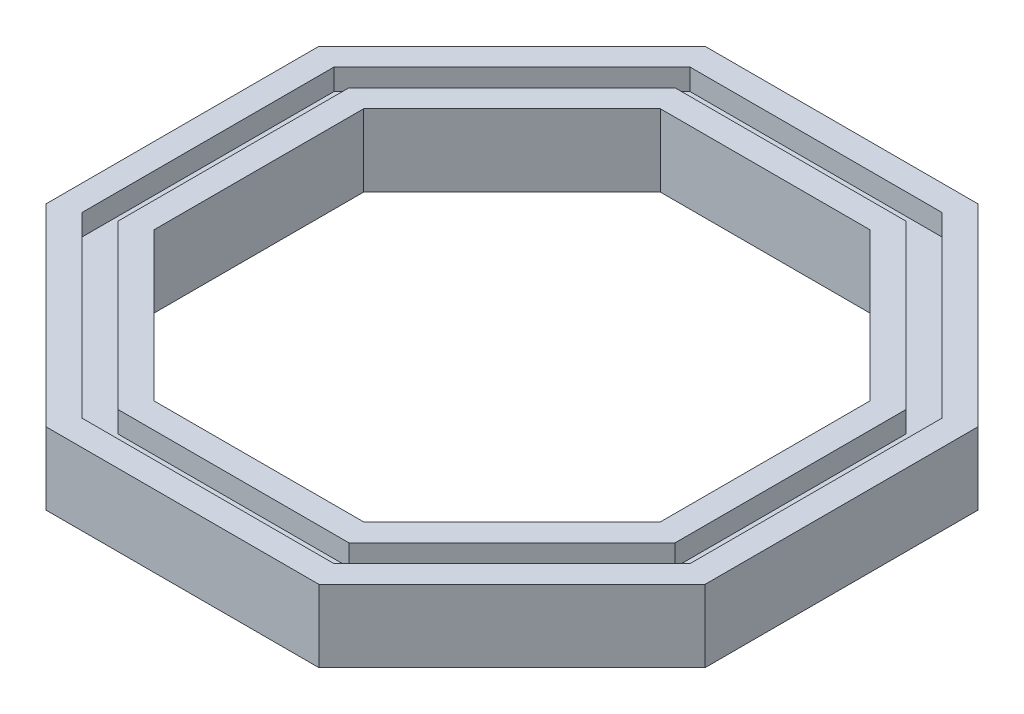
from build123d import *

# Parameters (mm, degrees)
EXTRUDE_1_DEPTH     = 1.7
CUT_EXTRUDE_3_DEPTH = 1
CUT_EXTRUDE_4_DEPTH = 2.7


with BuildPart() as part:
    # 스케치1 → 보스-돌출1 (new body)
    with BuildSketch(Plane(origin=(0, 0, 0), x_dir=(1, 0, 0), z_dir=(0, 1, 0))):
        Polygon((-15.520132754, -6.428649477), (-6.428649477, -15.520132754), (6.428649477, -15.520132754), (15.520132754, -6.428649477), (15.520132754, 6.428649477), (6.428649477, 15.520132754), (-6.428649477, 15.520132754), (-15.520132754, 6.428649477), align=None)
        Polygon((-5.931593202, -14.320132754), (5.931593202, -14.320132754), (14.320132754, -5.931593202), (14.320132754, 5.931593202), (5.931593202, 14.320132754), (-5.931593202, 14.320132754), (-14.320132754, 5.931593202), (-14.320132754, -5.931593202), align=None, mode=Mode.SUBTRACT)
        Polygon((-14.320132754, -5.931593202), (-5.931593202, -14.320132754), (5.931593202, -14.320132754), (14.320132754, -5.931593202), (14.320132754, 5.931593202), (5.931593202, 14.320132754), (-5.931593202, 14.320132754), (-14.320132754, 5.931593202), align=None)
        Polygon((-5.434536927, -13.120132754), (5.434536927, -13.120132754), (13.120132754, -5.434536927), (13.120132754, 5.434536927), (5.434536927, 13.120132754), (-5.434536927, 13.120132754), (-13.120132754, 5.434536927), (-13.120132754, -5.434536927), align=None, mode=Mode.SUBTRACT)
        Polygon((-13.120132754, -5.434536927), (-5.434536927, -13.120132754), (5.434536927, -13.120132754), (13.120132754, -5.434536927), (13.120132754, 5.434536927), (5.434536927, 13.120132754), (-5.434536927, 13.120132754), (-13.120132754, 5.434536927), align=None)
    extrude_1 = extrude(amount=EXTRUDE_1_DEPTH)

    # 스케치2 → 컷-돌출3 (cut)
    with BuildSketch(Plane(origin=(0, 1.7, 0), x_dir=(1, 0, 0), z_dir=(0, 1, 0))):
        Polygon((-14.320132754, -5.931593202), (-5.931593202, -14.320132754), (5.931593202, -14.320132754), (14.320132754, -5.931593202), (14.320132754, 5.931593202), (5.931593202, 14.320132754), (-5.931593202, 14.320132754), (-14.320132754, 5.931593202), align=None)
        Polygon((-13.120132754, -5.434536927), (-5.434536927, -13.120132754), (5.434536927, -13.120132754), (13.120132754, -5.434536927), (13.120132754, 5.434536927), (5.434536927, 13.120132754), (-5.434536927, 13.120132754), (-13.120132754, 5.434536927), align=None, mode=Mode.SUBTRACT)
    cut_extrude_3 = extrude(amount=-CUT_EXTRUDE_3_DEPTH, mode=Mode.SUBTRACT)

    # 스케치3 → 컷-돌출4 (cut, through all)
    with BuildSketch(Plane(origin=(0, 1.7, 0), x_dir=(1, 0, 0), z_dir=(0, 1, 0))):
        Polygon((-4.937480652, 11.920132754), (-11.920132754, 4.937480652), (-11.920132754, -4.937480652), (-4.937480652, -11.920132754), (4.937480652, -11.920132754), (11.920132754, -4.937480652), (11.920132754, 4.937480652), (4.937480652, 11.920132754), align=None)
    cut_extrude_4 = extrude(amount=-CUT_EXTRUDE_4_DEPTH, mode=Mode.SUBTRACT)

    # 대칭 복사1: 보스-돌출1, 컷-돌출3, 컷-돌출4 across plane
    add(extrude_1.mirror(Plane.ZX))
    add(cut_extrude_3.mirror(Plane.ZX), mode=Mode.SUBTRACT)
    add(cut_extrude_4.mirror(Plane.ZX), mode=Mode.SUBTRACT)


solid = part.part
